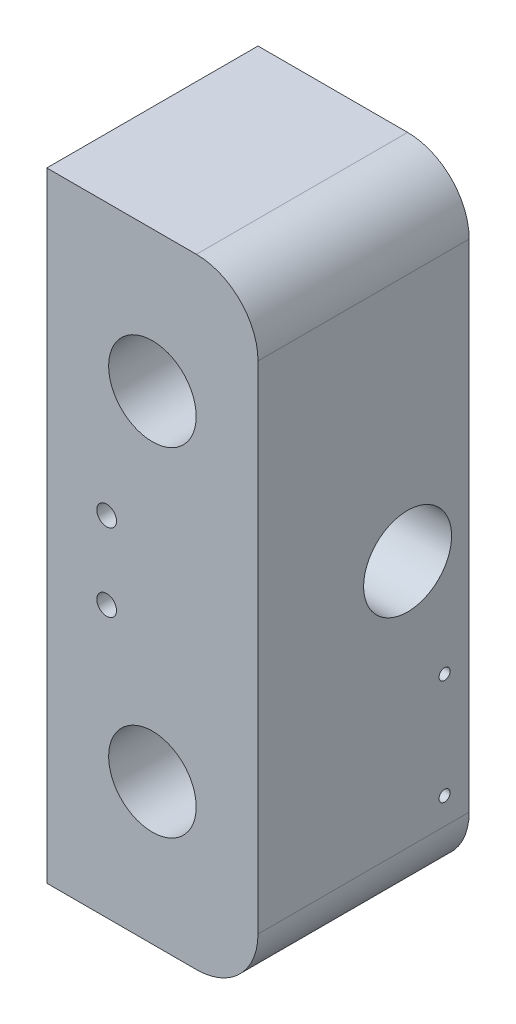
from build123d import *

# Parameters (mm, degrees)
SKETCH1_W               = 38.1
SKETCH1_H               = 38.1
BOSS_EXTRUDE1_DEPTH     = 111.76
SKETCH2_R               = 7.899999948
CUT_EXTRUDE1_DEPTH      = 1
CUT_EXTRUDE1_DEPTH_BACK = 39.1
SKETCH3_W               = 20.32
SKETCH3_H               = 22.86
CUT_EXTRUDE2_DEPTH      = 22.225
SKETCH5_R               = 1
CUT_EXTRUDE3_DEPTH      = 5.715
SKETCH6_R               = 7.9375
CUT_EXTRUDE4_DEPTH      = 21.32
CUT_EXTRUDE4_DEPTH_BACK = 18.78
SKETCH7_R               = 1.778
CUT_EXTRUDE5_DEPTH      = 23.225
CUT_EXTRUDE5_DEPTH_BACK = 16.875
CUT_EXTRUDE6_DEPTH      = 1
CUT_EXTRUDE6_DEPTH_BACK = 39.1


with BuildPart() as part:
    # Sketch1 → Boss-Extrude1 (new body)
    with BuildSketch(Plane(origin=(0, 0, 0), x_dir=(1, 0, 0), z_dir=(0, 1, 0))):
        Rectangle(SKETCH1_W, SKETCH1_H)
    extrude(amount=BOSS_EXTRUDE1_DEPTH)

    # Sketch2 → Cut-Extrude1 (cut, two sides)
    with BuildSketch(Plane.XY.offset(19.05)) as cut_extrude1_sk:
        with Locations((0, 86.4)):
            Circle(SKETCH2_R)
        with Locations((0, 25.4)):
            Circle(SKETCH2_R)
    extrude(amount=CUT_EXTRUDE1_DEPTH, mode=Mode.SUBTRACT)
    extrude(cut_extrude1_sk.sketch, amount=-CUT_EXTRUDE1_DEPTH_BACK, mode=Mode.SUBTRACT)

    # Sketch3 → Cut-Extrude2 (cut)
    with BuildSketch(Plane(origin=(0, 0, -19.05), x_dir=(-1, 0, 0), z_dir=(0, 0, -1))):
        with Locations((8.89, 55.88)):
            Rectangle(SKETCH3_W, SKETCH3_H)
    extrude(amount=-CUT_EXTRUDE2_DEPTH, mode=Mode.SUBTRACT)

    # Sketch5 → Cut-Extrude3 (cut)
    with BuildSketch(Plane(origin=(19.05, 0, 0), x_dir=(0, 0, -1), z_dir=(1, 0, 0))):
        with Locations((14.605, 34.9)):
            Circle(SKETCH5_R)
        with Locations((14.605, 15.9)):
            Circle(SKETCH5_R)
    extrude(amount=-CUT_EXTRUDE3_DEPTH, mode=Mode.SUBTRACT)

    # Sketch6 → Cut-Extrude4 (cut, two sides)
    with BuildSketch(Plane.ZY.offset(-1.27)) as cut_extrude4_sk:
        with Locations((-7.9375, 55.88)):
            Circle(SKETCH6_R)
    extrude(amount=CUT_EXTRUDE4_DEPTH, mode=Mode.SUBTRACT)
    extrude(cut_extrude4_sk.sketch, amount=-CUT_EXTRUDE4_DEPTH_BACK, mode=Mode.SUBTRACT)

    # Sketch7 → Cut-Extrude5 (cut, two sides)
    with BuildSketch(Plane(origin=(0, 0, 3.175), x_dir=(-1, 0, 0), z_dir=(0, 0, -1))) as cut_extrude5_sk:
        with Locations((8.255, 62.865)):
            Circle(SKETCH7_R)
        with Locations((8.255, 48.895)):
            Circle(SKETCH7_R)
    extrude(amount=CUT_EXTRUDE5_DEPTH, mode=Mode.SUBTRACT)
    extrude(cut_extrude5_sk.sketch, amount=-CUT_EXTRUDE5_DEPTH_BACK, mode=Mode.SUBTRACT)

    # Sketch8 → Cut-Extrude6 (cut, two sides)
    with BuildSketch(Plane(origin=(0, 0, -19.05), x_dir=(-1, 0, 0), z_dir=(0, 0, -1))) as cut_extrude6_sk:
        with BuildLine():
            ThreePointArc((-7.9375, 0), (-15.795224106, 3.254775894), (-19.05, 11.1125))
            Line((-19.05, 11.1125), (-19.05, 0))
            Line((-19.05, 0), (-7.9375, 0))
        make_face()
        with BuildLine():
            Line((-19.05, 111.76), (-19.05, 100.6475))
            ThreePointArc((-19.05, 100.6475), (-15.795224106, 108.505224106), (-7.9375, 111.76))
            Line((-7.9375, 111.76), (-19.05, 111.76))
        make_face()
    extrude(amount=CUT_EXTRUDE6_DEPTH, mode=Mode.SUBTRACT)
    extrude(cut_extrude6_sk.sketch, amount=-CUT_EXTRUDE6_DEPTH_BACK, mode=Mode.SUBTRACT)


solid = part.part
